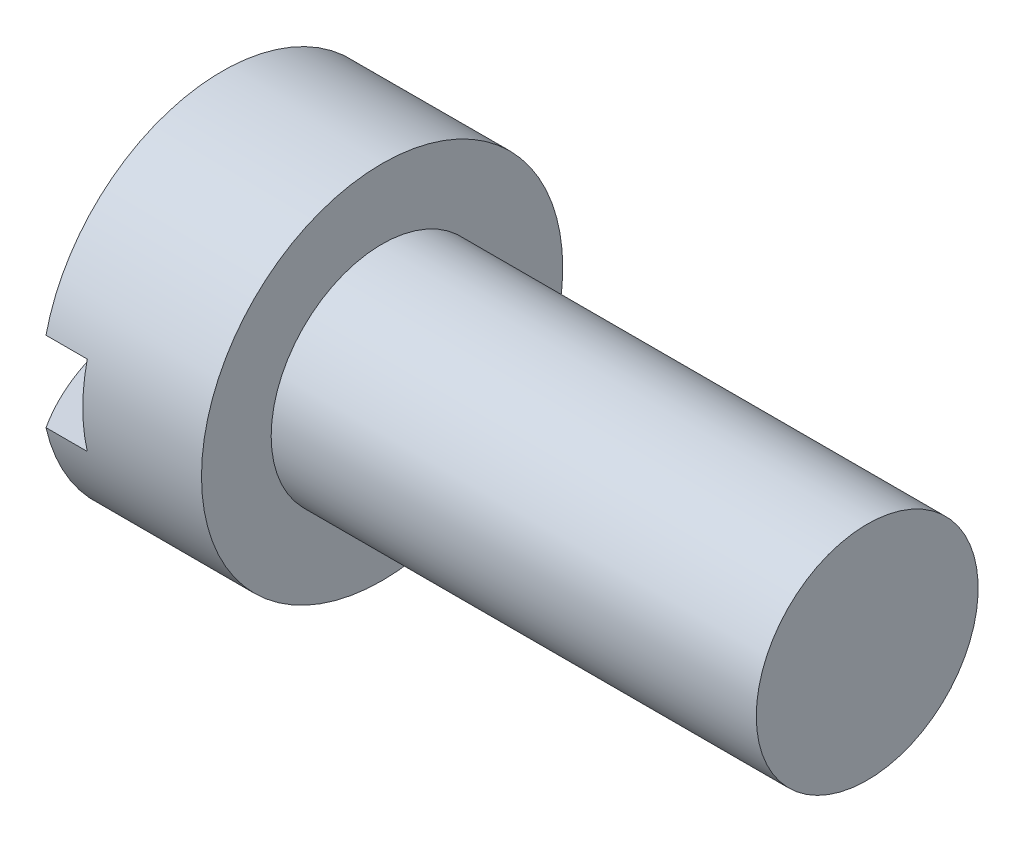
from build123d import *

# Parameters (mm, degrees)
SKETCH2_W  = 3.556
SKETCH2_H  = 0.7874
SLOT_DEPTH = 0.9398


with BuildPart() as part:
    # BodySke → Base-Revolve (revolve)
    with BuildSketch(Plane.XY, mode=Mode.PRIVATE) as base_revolve_sk:
        with BuildLine():
            Line((2.1082, 1.0922), (2.1082, 1.778))
            Line((2.1082, 1.778), (0.5334, 1.778))
            ThreePointArc((0.5334, 1.778), (0.136222505, 0.928143249), (0, 0))
            Line((0, 0), (6.8834, 0))
            Line((6.8834, 0), (6.8834, 1.0922))
            Line((6.8834, 1.0922), (2.1082, 1.0922))
        make_face()
    revolve(base_revolve_sk.sketch.rotate(Axis((-9.603521982, 0, 0), (1, 0, 0)), 90), axis=Axis((-9.603521982, 0, 0), (1, 0, 0)))  # turned: the seam where the file's is

    # Sketch2 → Slot (cut)
    with BuildSketch(Plane(origin=(0, 0, 0), x_dir=(0, 0, -1), z_dir=(1, 0, 0))):
        Rectangle(SKETCH2_W, SKETCH2_H)
    extrude(amount=SLOT_DEPTH, mode=Mode.SUBTRACT)


solid = part.part
